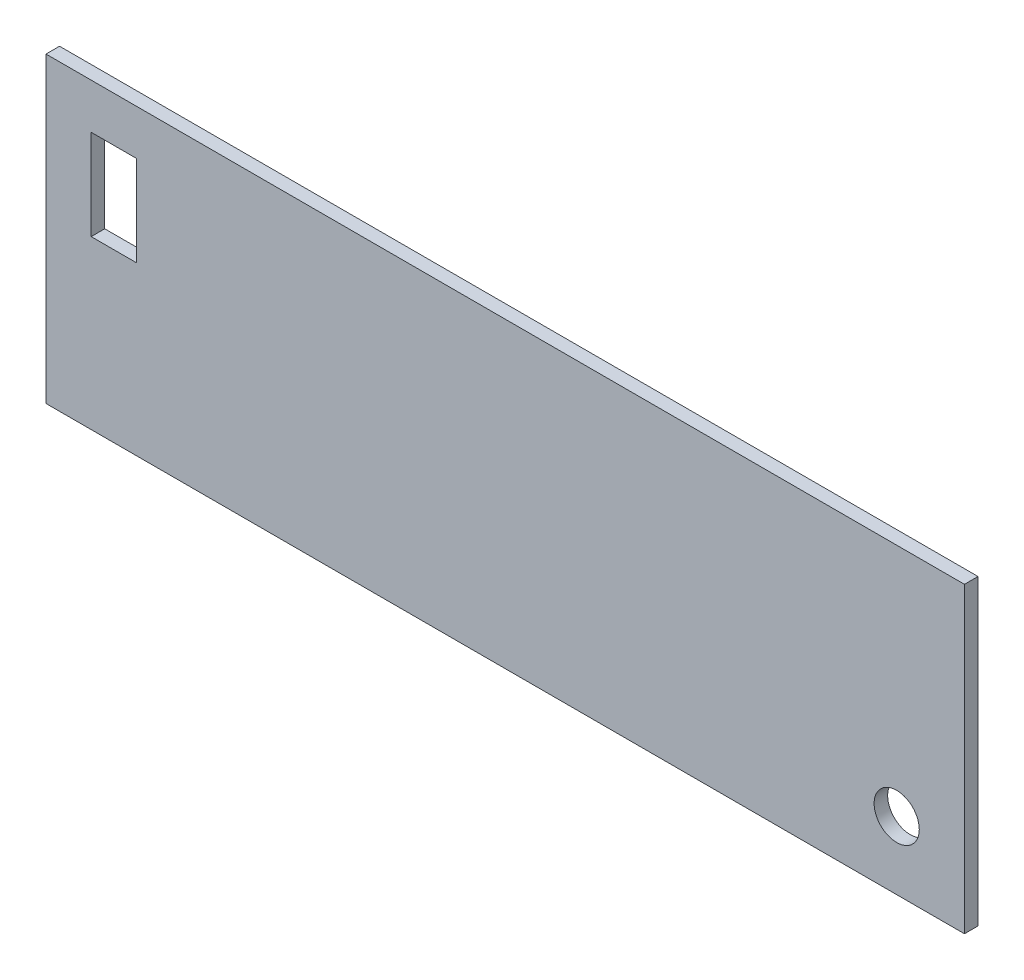
from build123d import *

# Parameters (mm, degrees)
CROQUIS1_W              = 203.31
CROQUIS1_H              = 67
SALIENTE_EXTRUIR1_DEPTH = 3
CORTAR_EXTRUIR1_REACH   = 5
CROQUIS2_W              = 10
CROQUIS2_H              = 20
CORTAR_EXTRUIR2_REACH   = 5
CROQUIS3_R              = 5


with BuildPart() as part:
    # Croquis1 → Saliente-Extruir1 (new body)
    with BuildSketch(Plane.XY):
        Rectangle(CROQUIS1_W, CROQUIS1_H)
    extrude(amount=-SALIENTE_EXTRUIR1_DEPTH)

    # Croquis2 → Cortar-Extruir1 (cut, up to next)
    with BuildSketch(Plane.XY, mode=Mode.PRIVATE) as cortar_extruir1_sk1:
        with Locations((-86.655, 13.5)):
            Rectangle(CROQUIS2_W, CROQUIS2_H)
    cortar_extruir1_tool1 = extrude(cortar_extruir1_sk1.sketch, amount=-CORTAR_EXTRUIR1_REACH, mode=Mode.PRIVATE) & part.part
    add(cortar_extruir1_tool1.solids().sort_by_distance((-86.655, 13.5, 0))[0], mode=Mode.SUBTRACT)

    # Croquis3 → Cortar-Extruir2 (cut, up to next)
    with BuildSketch(Plane.XY, mode=Mode.PRIVATE) as cortar_extruir2_sk1:
        with Locations((86.655, -18.5)):
            Circle(CROQUIS3_R)
    cortar_extruir2_tool1 = extrude(cortar_extruir2_sk1.sketch, amount=-CORTAR_EXTRUIR2_REACH, mode=Mode.PRIVATE) & part.part
    add(cortar_extruir2_tool1.solids().sort_by_distance((86.655, -18.5, 0))[0], mode=Mode.SUBTRACT)


solid = part.part
